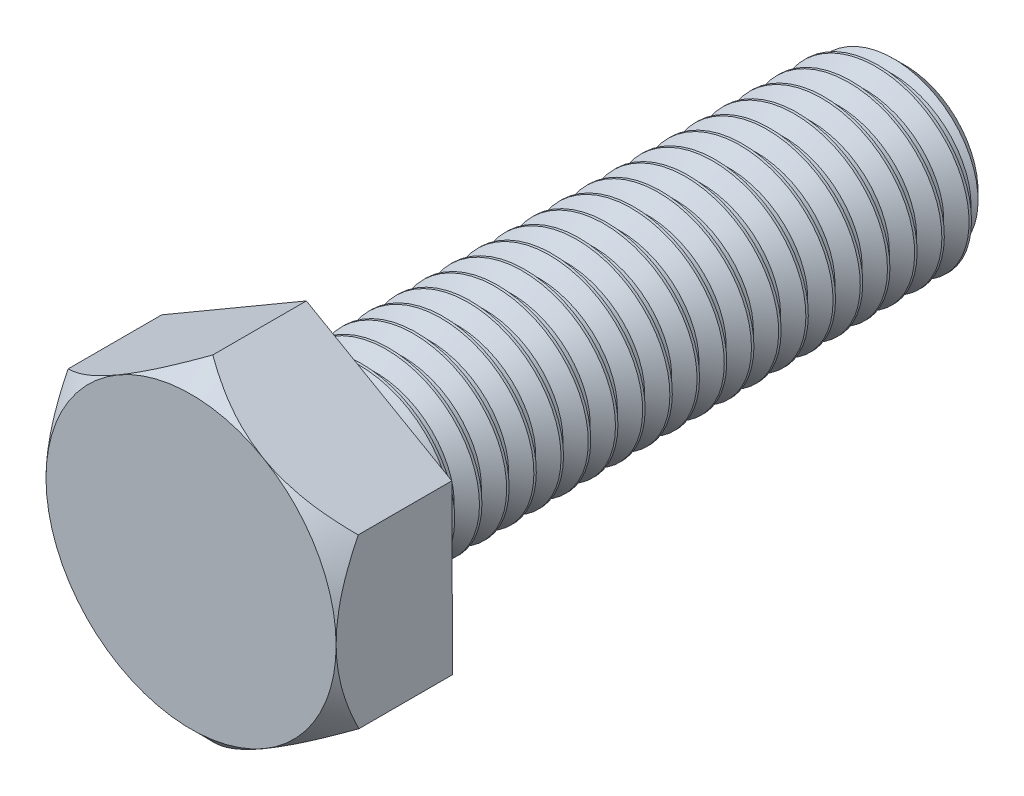
from build123d import *

# Parameters (mm, degrees)
BOSS_EXTRUDE2_DEPTH    = 6.4
SKETCH2_R              = 5
BOSS_EXTRUDE3_DEPTH    = 33
CHAMFER1_SIZE          = 1
CUT_SWEEP4_PITCH       = 1.5
CUT_SWEEP4_HEIGHT      = 31.5
CUT_SWEEP4_RADIUS      = 5
CUT_SWEEP4_START_ANGLE = 180
SKETCH10_OUTSIDE_W     = 47.318
SKETCH10_OUTSIDE_H     = 49.752
SKETCH10_OUTSIDE_R     = 8
CUT_EXTRUDE2_DEPTH     = 10
CUT_EXTRUDE2_DRAFT     = -45


with BuildPart() as part:
    # Sketch1 → Boss-Extrude2 (new body)
    with BuildSketch(Plane.XY):
        Polygon((7.979248, 4.654561), (-0.041344, 9.237512), (-8.020592, 4.582951), (-7.979248, -4.654561), (0.041344, -9.237512), (8.020592, -4.582951), align=None)
    extrude(amount=BOSS_EXTRUDE2_DEPTH)

    # Sketch2 → Boss-Extrude3 (add)
    with BuildSketch(Plane(origin=(0, 0, 0), x_dir=(-1, 0, 0), z_dir=(0, 0, -1))):
        Circle(SKETCH2_R)
    extrude(amount=BOSS_EXTRUDE3_DEPTH)

    # Chamfer1
    chamfer1_edges = [part.edges().sort_by_distance(p)[0] for p in [
        (5, 0, -33),
    ]]
    chamfer(chamfer1_edges, length=CHAMFER1_SIZE)

    # Cut-Sweep4: sweep along a helix
    with BuildLine() as cut_sweep4_path:
        add(Helix(CUT_SWEEP4_PITCH, CUT_SWEEP4_HEIGHT, CUT_SWEEP4_RADIUS, center=(0, 0, -33), direction=(0, 0, 1), mode=Mode.PRIVATE).rotate(Axis((0, 0, -33), (0, 0, 1)), CUT_SWEEP4_START_ANGLE))
    # Sketch9 → Cut-Sweep4 (sweep, cut)
    with BuildSketch(Plane(origin=(0, 0, 0), x_dir=(1, 0, 0), z_dir=(0, 1, 0))):
        Polygon((-4.237371, 33.118125), (-4.237371, 32.667367), (-5.736408, 32.110598), (-5.402041, 34.082449), align=None)
    sweep(path=cut_sweep4_path.line, is_frenet=True, mode=Mode.SUBTRACT)


with BuildPart() as cut_extrude2_tool:
    # Sketch10 outside → Cut-Extrude2 (with draft: the straight prism first)
    with BuildSketch(Plane.XY.offset(6.4)):
        Rectangle(SKETCH10_OUTSIDE_W, SKETCH10_OUTSIDE_H)
        Circle(SKETCH10_OUTSIDE_R, mode=Mode.SUBTRACT)
    extrude(amount=-CUT_EXTRUDE2_DEPTH)
    # Cut-Extrude2: the draft: its side faces are tilted about the plane it starts from
    cut_extrude2_sides = [cut_extrude2_tool.faces().sort_by_distance(p)[0] for p in [
        (0, -24.876, 1.4),
        (23.659, 0, 1.4),
        (0, 24.876, 1.4),
        (-23.659, 0, 1.4),
        (-8, 0, 1.4),
    ]]
    draft(cut_extrude2_sides, Plane.XY.offset(6.4), CUT_EXTRUDE2_DRAFT)


with BuildPart() as part_1:
    add(part.part)

    # Cut-Extrude2: cut by cut_extrude2_tool
    add(cut_extrude2_tool.part, mode=Mode.SUBTRACT)


solid = part_1.part
